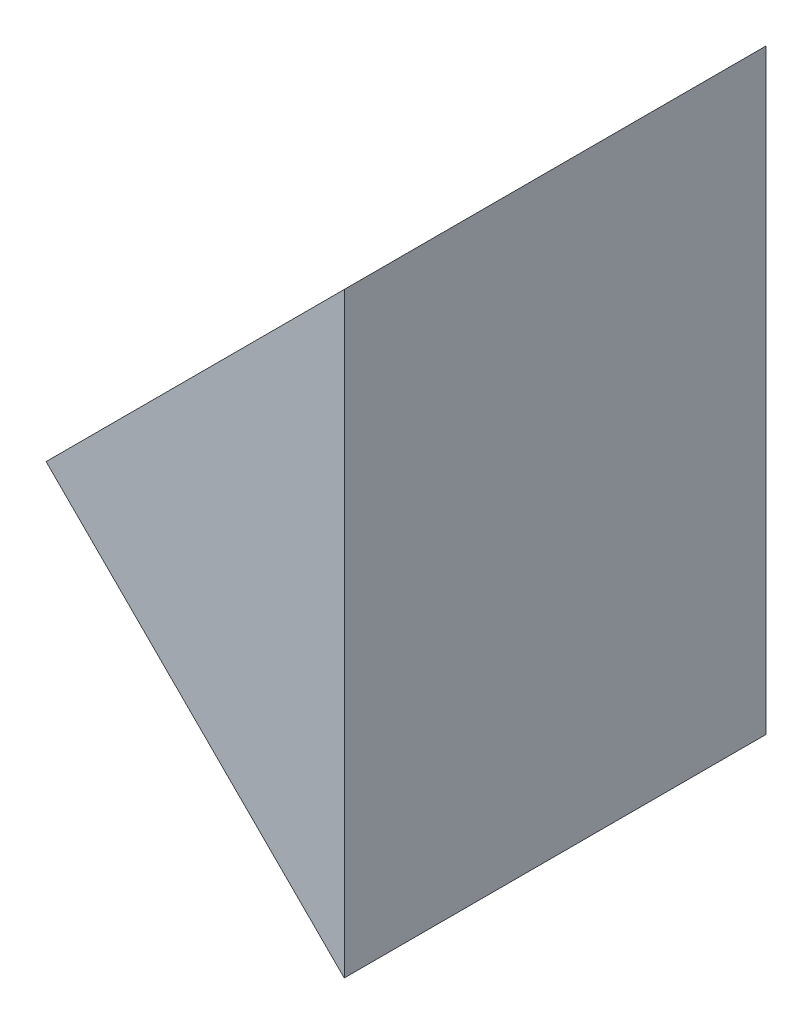
from build123d import *

# Parameters (mm, degrees)
EXTRUDE_1_DEPTH = 15


with BuildPart() as part:
    # 草图1 → 凸台-拉伸1 (new body)
    with BuildSketch(Plane.XY):
        Polygon((147.530509646, 45.045832973), (136.923907929, 34.439231255), (147.530509646, 23.832629537), align=None)
    extrude(amount=EXTRUDE_1_DEPTH)


solid = part.part
